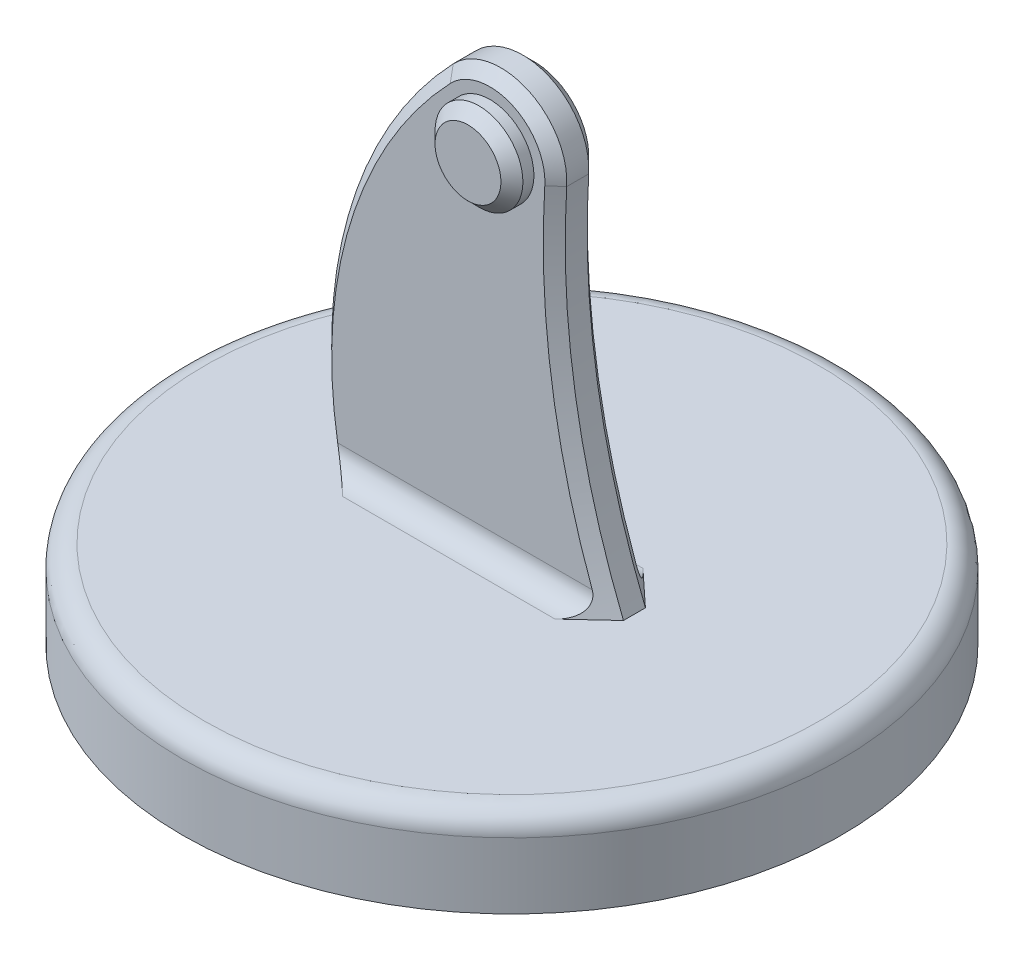
from build123d import *

# Parameters (mm, degrees)
SKETCH1_R           = 75
BOSS_EXTRUDE1_DEPTH = 20
FILLET1_R           = 5
BOSS_EXTRUDE2_DEPTH = 5
CHAMFER1_SIZE       = 2.5
FILLET2_R           = 5
SKETCH3_R           = 10
BOSS_EXTRUDE3_DEPTH = 5
CHAMFER2_SIZE       = 2.5
SKETCH4_R           = 5
CUT_EXTRUDE1_DEPTH  = 10


with BuildPart() as part:
    # Sketch1 → Boss-Extrude1 (new body)
    with BuildSketch(Plane(origin=(0, 0, 0), x_dir=(1, 0, 0), z_dir=(0, 1, 0))):
        Circle(SKETCH1_R)
    extrude(amount=BOSS_EXTRUDE1_DEPTH)

    # Fillet1
    fillet1_edges = [part.edges().sort_by_distance(p)[0] for p in [
        (-75, 20, 0),
    ]]
    fillet(fillet1_edges, radius=FILLET1_R)

    # Sketch2 → Boss-Extrude2 (add, symmetric)
    with BuildSketch(Plane.XY):
        with BuildLine():
            Line((-35, 15), (30, 15))
            ThreePointArc((30, 15), (17.428098582, 56.126843631), (14.970645506, 99.06203778))
            ThreePointArc((14.970645506, 99.06203778), (6.012327577, 113.742340307), (-10.849201429, 110.358321696))
            ThreePointArc((-10.849201429, 110.358321696), (-35.460543036, 65.854059614), (-35, 15))
        make_face()
    extrude(amount=BOSS_EXTRUDE2_DEPTH, both=True)

    # Chamfer1
    chamfer1_edges = [part.edges().sort_by_distance(p)[0] for p in [
        (16.970295051, 58.803839559, -5),
        (6.012327577, 113.742340307, -5),
        (-34.796467261, 68.341174934, -5),
        (16.970295051, 58.803839559, 5),
        (6.012327577, 113.742340307, 5),
        (-34.796467261, 68.341174934, 5),
    ]]
    chamfer(chamfer1_edges, length=CHAMFER1_SIZE)

    # Fillet2
    fillet2_edges = [part.edges().sort_by_distance(p)[0] for p in [
        (-4.241511046, 20, -5),
        (-4.241511046, 20, 5),
    ]]
    fillet(fillet2_edges, radius=FILLET2_R)

    # Sketch3 → Boss-Extrude3 (add)
    with BuildSketch(Plane.XY.offset(5)):
        with Locations((0, 100)):
            Circle(SKETCH3_R)
    extrude(amount=BOSS_EXTRUDE3_DEPTH)

    # Chamfer2
    chamfer2_edges = [part.edges().sort_by_distance(p)[0] for p in [
        (-10, 100, 10),
    ]]
    chamfer(chamfer2_edges, length=CHAMFER2_SIZE)

    # Sketch4 → Cut-Extrude1 (cut)
    with BuildSketch(Plane(origin=(0, 0, -5), x_dir=(-1, 0, 0), z_dir=(0, 0, -1))):
        with Locations((0, 100)):
            Circle(SKETCH4_R)
    extrude(amount=-CUT_EXTRUDE1_DEPTH, mode=Mode.SUBTRACT)


solid = part.part
